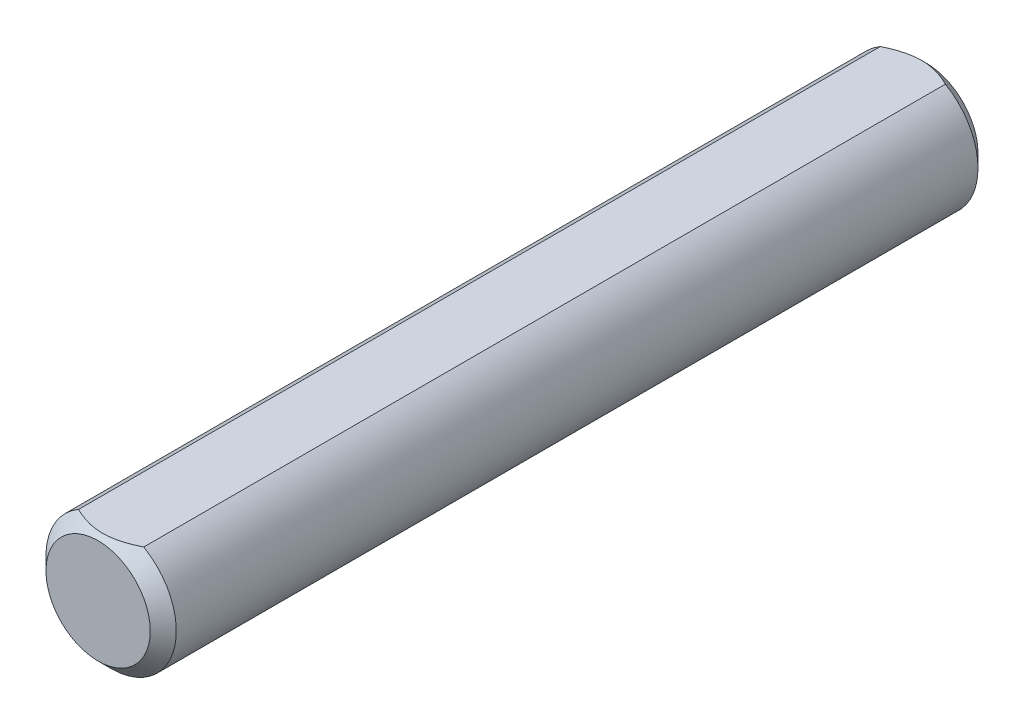
from build123d import *

# Parameters (mm, degrees)
SKETCH1_R           = 3
EXTRUDE1_DEPTH      = 19.05
CHAMFER1_SIZE       = 0.6
EXTRUDE7_DEPTH      = 20.05
EXTRUDE7_DEPTH_BACK = 20.05


with BuildPart() as part:
    # Sketch1 → Extrude1 (new body, symmetric)
    with BuildSketch(Plane.XY):
        Circle(SKETCH1_R)
    extrude(amount=EXTRUDE1_DEPTH, both=True)

    # Chamfer1
    chamfer1_edges = [part.edges().sort_by_distance(p)[0] for p in [
        (-3, 0, -19.05),
        (-3, 0, 19.05),
    ]]
    chamfer(chamfer1_edges, length=CHAMFER1_SIZE)

    # Sketch13 → Extrude7 (cut, two sides)
    with BuildSketch(Plane.XY) as extrude7_sk:
        with BuildLine():
            Line((-1.5, 2.598076211), (1.5, 2.598076211))
            ThreePointArc((1.5, 2.598076211), (0, 3), (-1.5, 2.598076211))
        make_face()
    extrude(amount=EXTRUDE7_DEPTH, mode=Mode.SUBTRACT)
    extrude(extrude7_sk.sketch, amount=-EXTRUDE7_DEPTH_BACK, mode=Mode.SUBTRACT)


solid = part.part
